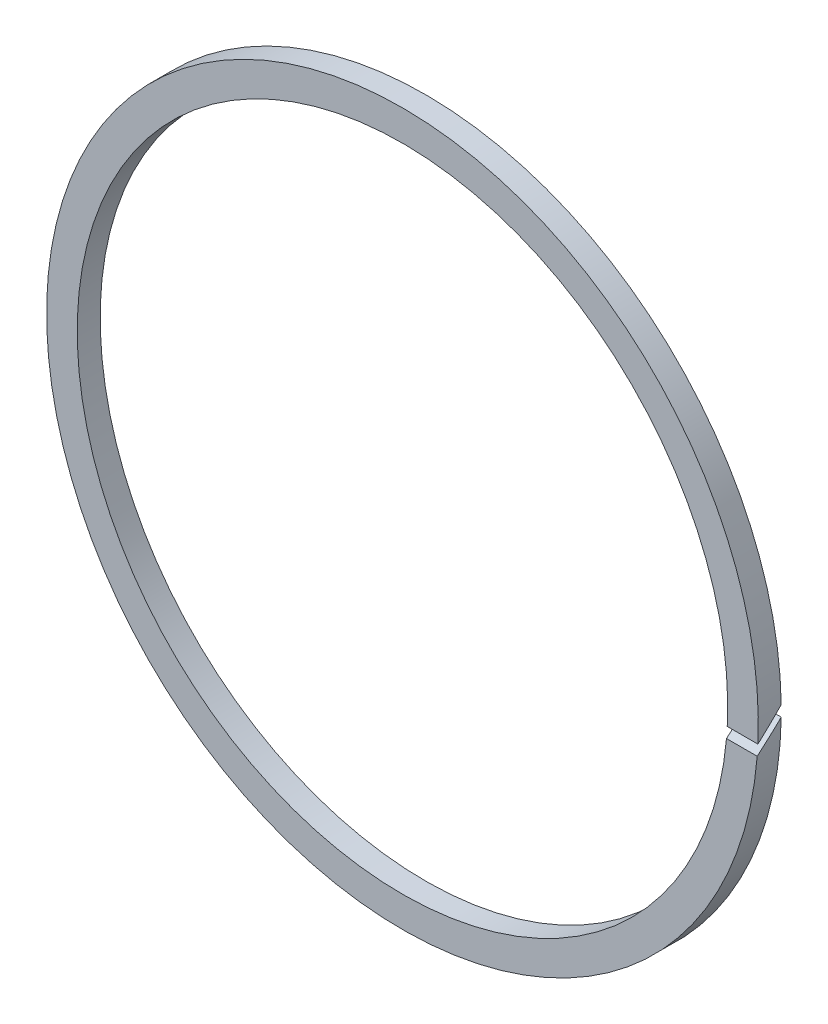
from build123d import *

# Parameters (mm, degrees)
SKETCH1_R               = 46.5
SKETCH1_R_2             = 42.5
BOSS_EXTRUDE1_DEPTH     = 3
CUT_EXTRUDE2_REACH      = 67.829
CUT_EXTRUDE2_END_RADIUS = 46.5


with BuildPart() as part:
    # Sketch1 → Boss-Extrude1 (new body)
    with BuildSketch(Plane.XY):
        Circle(SKETCH1_R)
        Circle(SKETCH1_R_2, mode=Mode.SUBTRACT)
    extrude(amount=BOSS_EXTRUDE1_DEPTH)

    # Cut-Extrude2: up to this cylinder (the profile starts inside it)
    cut_extrude2_end = Plane(origin=(0, 0, -0.237725), z_dir=(0, 0, -1)) * Cylinder(CUT_EXTRUDE2_END_RADIUS, 229.658, mode=Mode.PRIVATE)
    # Sketch2 → Cut-Extrude2 (cut, up to the surface)
    with BuildSketch(Plane(origin=(0, 0, 0), x_dir=(0, 0, -1), z_dir=(1, 0, 0)), mode=Mode.PRIVATE) as cut_extrude2_sk1:
        Polygon((-14.60888812, -13.901781339), (14.377231128, 15.08433791), (15.08433791, 14.377231128), (-13.901781339, -14.60888812), align=None)
    cut_extrude2_tool1 = extrude(cut_extrude2_sk1.sketch, amount=CUT_EXTRUDE2_REACH, mode=Mode.PRIVATE) & cut_extrude2_end
    add(cut_extrude2_tool1.solids().sort_by_distance((0, 0.237725, -0.237725))[0], mode=Mode.SUBTRACT)


solid = part.part
